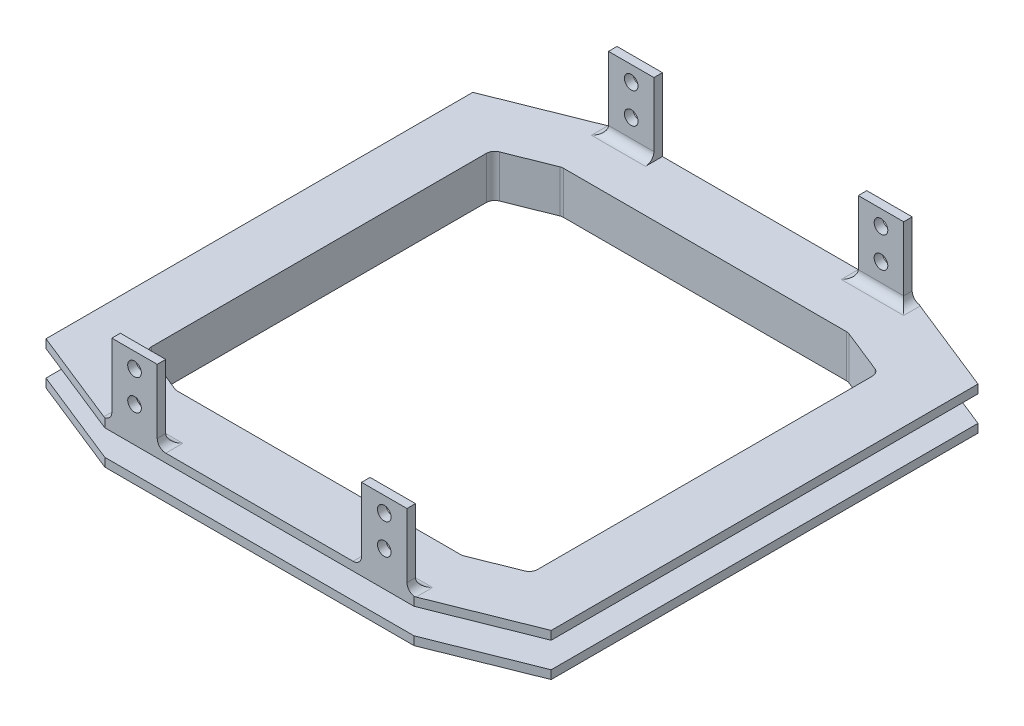
from build123d import *

# Parameters (mm, degrees)
BOSS_EXTRUDE1_DEPTH     = 2.25
BOSS_EXTRUDE2_DEPTH     = 1.5
CUT_EXTRUDE1_DEPTH      = 4.75
CUT_EXTRUDE1_DEPTH_BACK = 4.75
BOSS_EXTRUDE3_START     = 44.5
SKETCH5_W               = 8
SKETCH5_H               = 12.8
BOSS_EXTRUDE3_DEPTH     = 1.5
BOSS_EXTRUDE4_START     = -44.5
SKETCH5_2_W             = 8
SKETCH5_2_H             = 12.8
BOSS_EXTRUDE4_DEPTH     = 1.5
SKETCH6_R               = 1.2
CUT_EXTRUDE3_DEPTH      = 45.5
CUT_EXTRUDE3_DEPTH_BACK = 45.5
FILLET1_R               = 1.5
FILLET2_R               = 1.5


with BuildPart() as part:
    # Sketch1 → Boss-Extrude1 (new body, symmetric)
    with BuildSketch(Plane(origin=(0, 0, 0), x_dir=(1, 0, 0), z_dir=(0, 1, 0))):
        Polygon((-25.5, -35.5), (25.5, -35.5), (35.5, -31.5), (35.5, 31.5), (25.5, 35.5), (-25.5, 35.5), (-35.5, 31.5), (-35.5, -31.5), align=None)
    extrude(amount=BOSS_EXTRUDE1_DEPTH, both=True)

    # Sketch2 → Boss-Extrude2 (add)
    with BuildSketch(Plane(origin=(0, 2.25, 0), x_dir=(1, 0, 0), z_dir=(0, 1, 0))):
        Polygon((27.233241632, -44.5), (44.5, -37.593296653), (44.5, 37.593296653), (27.233241632, 44.5), (-27.233241632, 44.5), (-44.5, 37.593296653), (-44.5, -37.593296653), (-27.233241632, -44.5), align=None)
    boss_extrude2 = extrude(amount=BOSS_EXTRUDE2_DEPTH)

    # Mirror1: Boss-Extrude2 across plane
    add(boss_extrude2.mirror(Plane.ZX))

    # Sketch3 → Cut-Extrude1 (cut, two sides)
    with BuildSketch(Plane(origin=(0, 0, 0), x_dir=(1, 0, 0), z_dir=(0, 1, 0))) as cut_extrude1_sk:
        Polygon((-25.211126395, -34), (25.211126395, -34), (34, -30.484450558), (34, 30.484450558), (25.211126395, 34), (-25.211126395, 34), (-34, 30.484450558), (-34, -30.484450558), align=None)
    extrude(amount=CUT_EXTRUDE1_DEPTH, mode=Mode.SUBTRACT)
    extrude(cut_extrude1_sk.sketch, amount=-CUT_EXTRUDE1_DEPTH_BACK, mode=Mode.SUBTRACT)

    # Sketch5 → Boss-Extrude3 (add)
    with BuildSketch(Plane.XY.offset(BOSS_EXTRUDE3_START)):
        with Locations((-22, 10.15)):
            Rectangle(SKETCH5_W, SKETCH5_H)
        with Locations((22, 10.15)):
            Rectangle(SKETCH5_W, SKETCH5_H)
    extrude(amount=-BOSS_EXTRUDE3_DEPTH)

    # Sketch5_2 → Boss-Extrude4 (add)
    with BuildSketch(Plane.XY.offset(BOSS_EXTRUDE4_START)):
        with Locations((-22, 10.15)):
            Rectangle(SKETCH5_2_W, SKETCH5_2_H)
        with Locations((22, 10.15)):
            Rectangle(SKETCH5_2_W, SKETCH5_2_H)
    extrude(amount=BOSS_EXTRUDE4_DEPTH)

    # Sketch6 → Cut-Extrude3 (cut, two sides)
    with BuildSketch(Plane.XY) as cut_extrude3_sk:
        with Locations((-22, 13.85)):
            Circle(SKETCH6_R)
        with Locations((22, 13.85)):
            Circle(SKETCH6_R)
        with Locations((-22, 8.45)):
            Circle(SKETCH6_R)
        with Locations((22, 8.45)):
            Circle(SKETCH6_R)
    extrude(amount=CUT_EXTRUDE3_DEPTH, mode=Mode.SUBTRACT)
    extrude(cut_extrude3_sk.sketch, amount=-CUT_EXTRUDE3_DEPTH_BACK, mode=Mode.SUBTRACT)

    # Fillet1
    fillet1_edges = [part.edges().sort_by_distance(p)[0] for p in [
        (35.5, 0, 31.5),
        (25.5, 0, 35.5),
        (0, 2.25, -35.5),
        (0, -2.25, -35.5),
        (35.5, 2.25, 0),
        (35.5, -2.25, 0),
        (-35.5, 2.25, 0),
        (-35.5, -2.25, 0),
        (0, 2.25, 35.5),
        (0, -2.25, 35.5),
        (-25.5, 0, -35.5),
        (-30.5, 2.25, -33.5),
        (-35.5, 0, -31.5),
        (-30.5, -2.25, -33.5),
        (35.5, 0, -31.5),
        (30.5, 2.25, -33.5),
        (25.5, 0, -35.5),
        (30.5, -2.25, -33.5),
        (30.5, 2.25, 33.5),
        (30.5, -2.25, 33.5),
        (-35.5, 0, 31.5),
        (-30.5, 2.25, 33.5),
        (-25.5, 0, 35.5),
        (-30.5, -2.25, 33.5),
        (-22, 3.75, -43),
        (22, 3.75, -43),
        (-22, 3.75, 43),
        (22, 3.75, 43),
        (26, 3.75, 43.75),
        (-18, 3.75, 43.75),
        (18, 3.75, 43.75),
        (-26, 3.75, 43.75),
        (18, 3.75, -43.75),
        (26, 3.75, -43.75),
        (-26, 3.75, -43.75),
    ]]
    fillet(fillet1_edges, radius=FILLET1_R)

    # Fillet2
    fillet2_edges = [part.edges().sort_by_distance(p)[0] for p in [
        (-25.211126395, 0, 34),
        (-34, 0, 30.484450558),
        (-34, 0, -30.484450558),
        (-25.211126395, 0, -34),
        (25.211126395, 0, -34),
        (34, 0, -30.484450558),
        (34, 0, 30.484450558),
        (25.211126395, 0, 34),
    ]]
    fillet(fillet2_edges, radius=FILLET2_R)


solid = part.part
